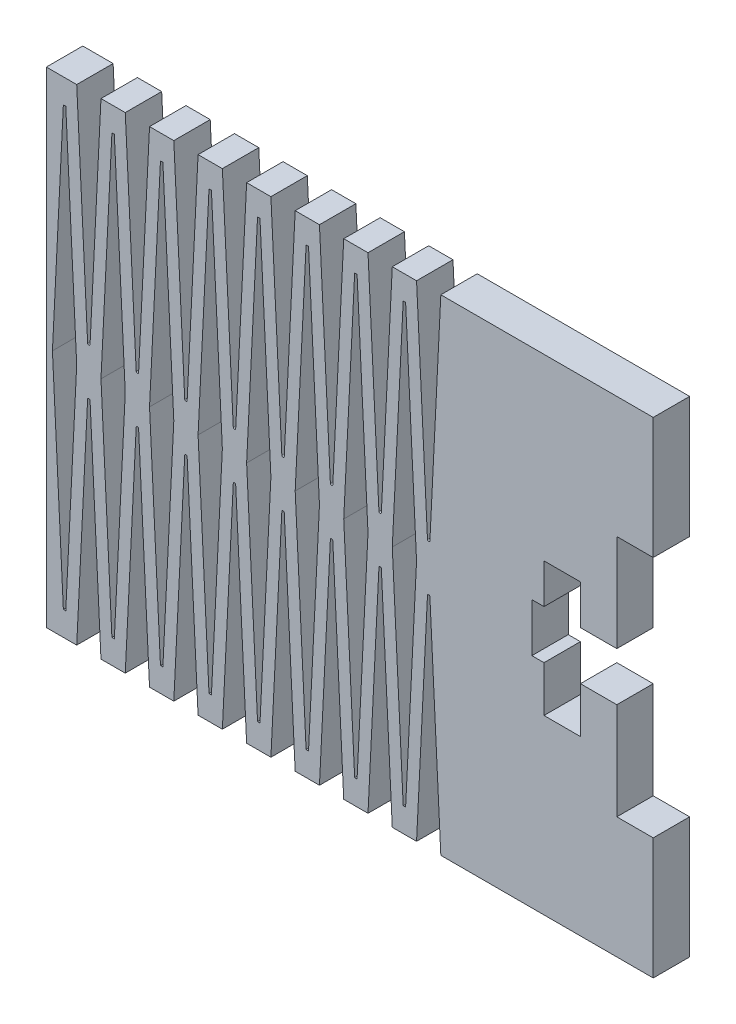
from build123d import *

# Parameters (mm, degrees)
EXTRUDE_1_DEPTH = 1.5


with BuildPart() as part:
    # 草图1 → 凸台-拉伸1 (new body, symmetric)
    with BuildSketch(Plane.XY):
        with BuildLine():
            Line((-22.5, 20), (-25, 20))
            Line((-25, 20), (-25, -20))
            Line((-25, -20), (-22.5, -20))
            Line((-22.5, -20), (-21.599875234, -1.997504678))
            ThreePointArc((-21.599875234, -1.997504678), (-21.5, -1.902498439), (-21.400124766, -1.997504678))
            Line((-21.400124766, -1.997504678), (-20.5, -20))
            Line((-20.5, -20), (-18.5, -20))
            Line((-18.5, -20), (-17.599875234, -1.997504678))
            ThreePointArc((-17.599875234, -1.997504678), (-17.5, -1.902498439), (-17.400124766, -1.997504678))
            Line((-17.400124766, -1.997504678), (-16.5, -20))
            Line((-16.5, -20), (-14.5, -20))
            Line((-14.5, -20), (-13.599875234, -1.997504678))
            ThreePointArc((-13.599875234, -1.997504678), (-13.5, -1.902498439), (-13.400124766, -1.997504678))
            Line((-13.400124766, -1.997504678), (-12.5, -20))
            Line((-12.5, -20), (-10.5, -20))
            Line((-10.5, -20), (-9.599875234, -1.997504678))
            ThreePointArc((-9.599875234, -1.997504678), (-9.5, -1.902498439), (-9.400124766, -1.997504678))
            Line((-9.400124766, -1.997504678), (-8.5, -20))
            Line((-8.5, -20), (-6.5, -20))
            Line((-6.5, -20), (-5.599875234, -1.997504678))
            ThreePointArc((-5.599875234, -1.997504678), (-5.5, -1.902498439), (-5.400124766, -1.997504678))
            Line((-5.400124766, -1.997504678), (-4.5, -20))
            Line((-4.5, -20), (-2.5, -20))
            Line((-2.5, -20), (-1.599875234, -1.997504678))
            ThreePointArc((-1.599875234, -1.997504678), (-1.5, -1.902498439), (-1.400124766, -1.997504678))
            Line((-1.400124766, -1.997504678), (-0.5, -20))
            Line((-0.5, -20), (1.5, -20))
            Line((1.5, -20), (2.400124766, -1.997504678))
            ThreePointArc((2.400124766, -1.997504678), (2.5, -1.902498439), (2.599875234, -1.997504678))
            Line((2.599875234, -1.997504678), (3.5, -20))
            Line((3.5, -20), (5.5, -20))
            Line((5.5, -20), (6.400124766, -1.997504678))
            ThreePointArc((6.400124766, -1.997504678), (6.5, -1.902498439), (6.599875234, -1.997504678))
            Line((6.599875234, -1.997504678), (7.5, -20))
            Line((7.5, -20), (25, -20))
            Line((25, -20), (25, -10))
            Line((25, -10), (22, -10))
            Line((22, -10), (22, -2))
            Line((22, -2), (19, -2))
            Line((19, -2), (19, -5.769694942))
            Line((19, -5.769694942), (16, -5.769694942))
            Line((16, -5.769694942), (16, -2))
            Line((16, -2), (15, -2))
            Line((15, -2), (15, 2))
            Line((15, 2), (16, 2))
            Line((16, 2), (16, 5.265909841))
            Line((16, 5.265909841), (19, 5.265909841))
            Line((19, 5.265909841), (19, 2))
            Line((19, 2), (22, 2))
            Line((22, 2), (22, 10))
            Line((22, 10), (25, 10))
            Line((25, 10), (25, 20))
            Line((25, 20), (7.5, 20))
            Line((7.5, 20), (6.599875234, 1.997504678))
            ThreePointArc((6.599875234, 1.997504678), (6.5, 1.902498439), (6.400124766, 1.997504678))
            Line((6.400124766, 1.997504678), (5.5, 20))
            Line((5.5, 20), (3.5, 20))
            Line((3.5, 20), (2.599875234, 1.997504678))
            ThreePointArc((2.599875234, 1.997504678), (2.5, 1.902498439), (2.400124766, 1.997504678))
            Line((2.400124766, 1.997504678), (1.5, 20))
            Line((1.5, 20), (-0.5, 20))
            Line((-0.5, 20), (-1.400124766, 1.997504678))
            ThreePointArc((-1.400124766, 1.997504678), (-1.5, 1.902498439), (-1.599875234, 1.997504678))
            Line((-1.599875234, 1.997504678), (-2.5, 20))
            Line((-2.5, 20), (-4.5, 20))
            Line((-4.5, 20), (-5.400124766, 1.997504678))
            ThreePointArc((-5.400124766, 1.997504678), (-5.5, 1.902498439), (-5.599875234, 1.997504678))
            Line((-5.599875234, 1.997504678), (-6.5, 20))
            Line((-6.5, 20), (-8.5, 20))
            Line((-8.5, 20), (-9.400124766, 1.997504678))
            ThreePointArc((-9.400124766, 1.997504678), (-9.5, 1.902498439), (-9.599875234, 1.997504678))
            Line((-9.599875234, 1.997504678), (-10.5, 20))
            Line((-10.5, 20), (-12.5, 20))
            Line((-12.5, 20), (-13.400124766, 1.997504678))
            ThreePointArc((-13.400124766, 1.997504678), (-13.5, 1.902498439), (-13.599875234, 1.997504678))
            Line((-13.599875234, 1.997504678), (-14.5, 20))
            Line((-14.5, 20), (-16.5, 20))
            Line((-16.5, 20), (-17.400124766, 1.997504678))
            ThreePointArc((-17.400124766, 1.997504678), (-17.5, 1.902498439), (-17.599875234, 1.997504678))
            Line((-17.599875234, 1.997504678), (-18.5, 20))
            Line((-18.5, 20), (-20.5, 20))
            Line((-20.5, 20), (-21.400124766, 1.997504678))
            ThreePointArc((-21.400124766, 1.997504678), (-21.5, 1.902498439), (-21.599875234, 1.997504678))
            Line((-21.599875234, 1.997504678), (-22.5, 20))
        make_face()
        Polygon((4.599875234, 18.002495322), (5.5, 0), (4.599875234, -18.002495322), (4.400124766, -18.002495322), (3.5, 0), (4.400124766, 18.002495322), align=None, mode=Mode.SUBTRACT)
        Polygon((0.599875234, -18.002495322), (0.400124766, -18.002495322), (-0.5, 0), (0.400124766, 18.002495322), (0.599875234, 18.002495322), (1.5, 0), align=None, mode=Mode.SUBTRACT)
        Polygon((-3.400124766, -18.002495322), (-3.599875234, -18.002495322), (-4.5, 0), (-3.599875234, 18.002495322), (-3.400124766, 18.002495322), (-2.5, 0), align=None, mode=Mode.SUBTRACT)
        Polygon((-7.400124766, -18.002495322), (-7.599875234, -18.002495322), (-8.5, 0), (-7.599875234, 18.002495322), (-7.400124766, 18.002495322), (-6.5, 0), align=None, mode=Mode.SUBTRACT)
        Polygon((-11.400124766, -18.002495322), (-11.599875234, -18.002495322), (-12.5, 0), (-11.599875234, 18.002495322), (-11.400124766, 18.002495322), (-10.5, 0), align=None, mode=Mode.SUBTRACT)
        Polygon((-15.400124766, -18.002495322), (-15.599875234, -18.002495322), (-16.5, 0), (-15.599875234, 18.002495322), (-15.400124766, 18.002495322), (-14.5, 0), align=None, mode=Mode.SUBTRACT)
        Polygon((-19.400124766, -18.002495322), (-19.599875234, -18.002495322), (-20.5, 0), (-19.599875234, 18.002495322), (-19.400124766, 18.002495322), (-18.5, 0), align=None, mode=Mode.SUBTRACT)
        Polygon((-23.400124766, -18.002495322), (-23.599875234, -18.002495322), (-24.5, 0), (-23.599875234, 18.002495322), (-23.400124766, 18.002495322), (-22.5, 0), align=None, mode=Mode.SUBTRACT)
    extrude(amount=EXTRUDE_1_DEPTH, both=True)


solid = part.part
